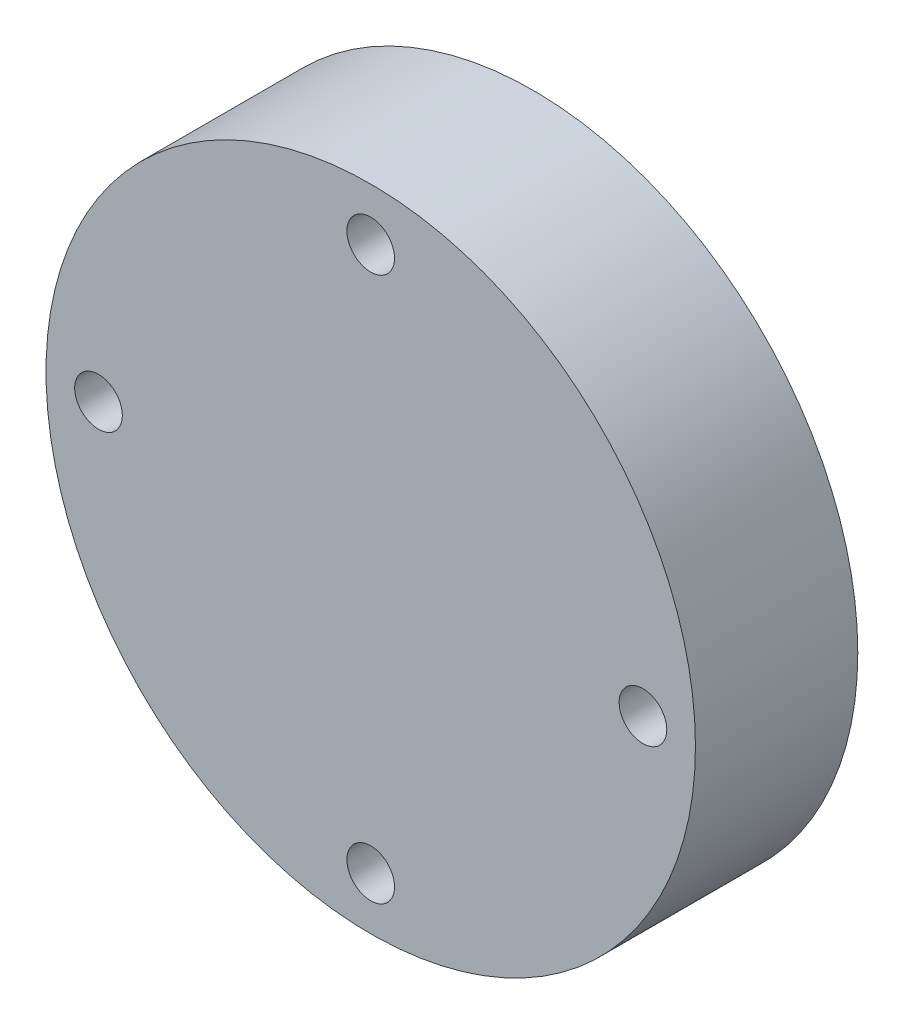
from build123d import *

# Parameters (mm, degrees)
SKETCH1_R           = 30
BOSS_EXTRUDE1_DEPTH = 15
SKETCH2_R           = 2.2
CUT_EXTRUDE1_DEPTH  = 15
SKETCH3_R           = 4
CUT_EXTRUDE2_DEPTH  = 4.5
SKETCH5_R           = 8
BOSS_EXTRUDE2_DEPTH = 1.5
SKETCH8_R           = 3.25
CUT_EXTRUDE3_DEPTH  = 7


with BuildPart() as part:
    # Sketch1 → Boss-Extrude1 (new body)
    with BuildSketch(Plane.XY):
        Circle(SKETCH1_R)
    extrude(amount=BOSS_EXTRUDE1_DEPTH)

    # Sketch2 → Cut-Extrude1 (cut)
    with BuildSketch(Plane.XY):
        with Locations((0, 25.15)):
            Circle(SKETCH2_R)
        with Locations((25.15, 0)):
            Circle(SKETCH2_R)
        with Locations((0, -25.15)):
            Circle(SKETCH2_R)
        with Locations((-25.15, 0)):
            Circle(SKETCH2_R)
    extrude(amount=CUT_EXTRUDE1_DEPTH, mode=Mode.SUBTRACT)

    # Sketch3 → Cut-Extrude2 (cut)
    with BuildSketch(Plane.XY):
        with Locations((0, 25.15)):
            Circle(SKETCH3_R)
        with Locations((25.15, 0)):
            Circle(SKETCH3_R)
        with Locations((0, -25.15)):
            Circle(SKETCH3_R)
        with Locations((-25.15, 0)):
            Circle(SKETCH3_R)
    extrude(amount=CUT_EXTRUDE2_DEPTH, mode=Mode.SUBTRACT)

    # Sketch5 → Boss-Extrude2 (add)
    with BuildSketch(Plane.XY):
        Circle(SKETCH5_R)
    extrude(amount=-BOSS_EXTRUDE2_DEPTH)

    # Sketch8 → Cut-Extrude3 (cut)
    with BuildSketch(Plane.XY.offset(-1.5)):
        Circle(SKETCH8_R)
    extrude(amount=CUT_EXTRUDE3_DEPTH, mode=Mode.SUBTRACT)


solid = part.part
